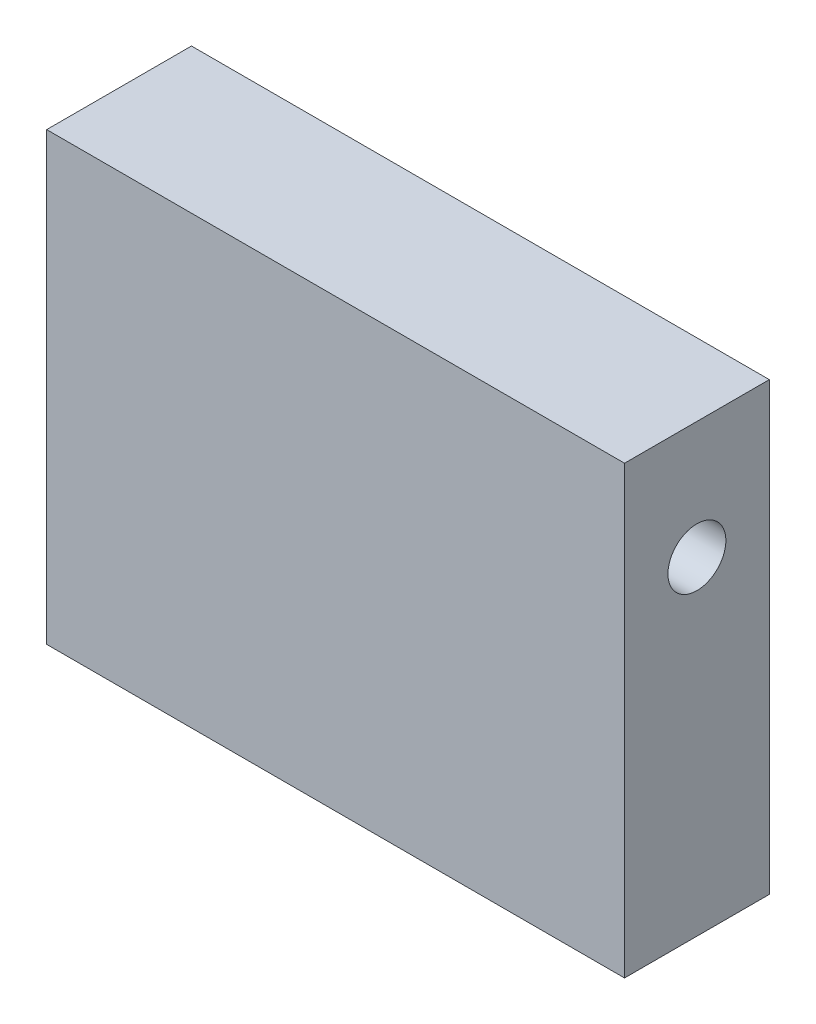
from build123d import *

# Parameters (mm, degrees)
SKETCH1_W           = 79.816604327
SKETCH1_H           = 61.580684207
BOSS_EXTRUDE1_DEPTH = 20
CUT_EXTRUDE1_START  = -18.943875
SKETCH3_R           = 4
CUT_EXTRUDE1_DEPTH  = 80.816604514


with BuildPart() as part:
    # Sketch1 → Boss-Extrude1 (new body)
    with BuildSketch(Plane.XY):
        with Locations((-58.852177351, -19.652156424)):
            Rectangle(SKETCH1_W, SKETCH1_H)
    extrude(amount=BOSS_EXTRUDE1_DEPTH)

    # Sketch3 → Cut-Extrude1 (cut, through all)
    with BuildSketch(Plane(origin=(0, 0, 0), x_dir=(0, 0, -1), z_dir=(1, 0, 0)).offset(CUT_EXTRUDE1_START)):
        with Locations((-10, -5.101602078)):
            Circle(SKETCH3_R)
    extrude(amount=-CUT_EXTRUDE1_DEPTH, mode=Mode.SUBTRACT)


solid = part.part
